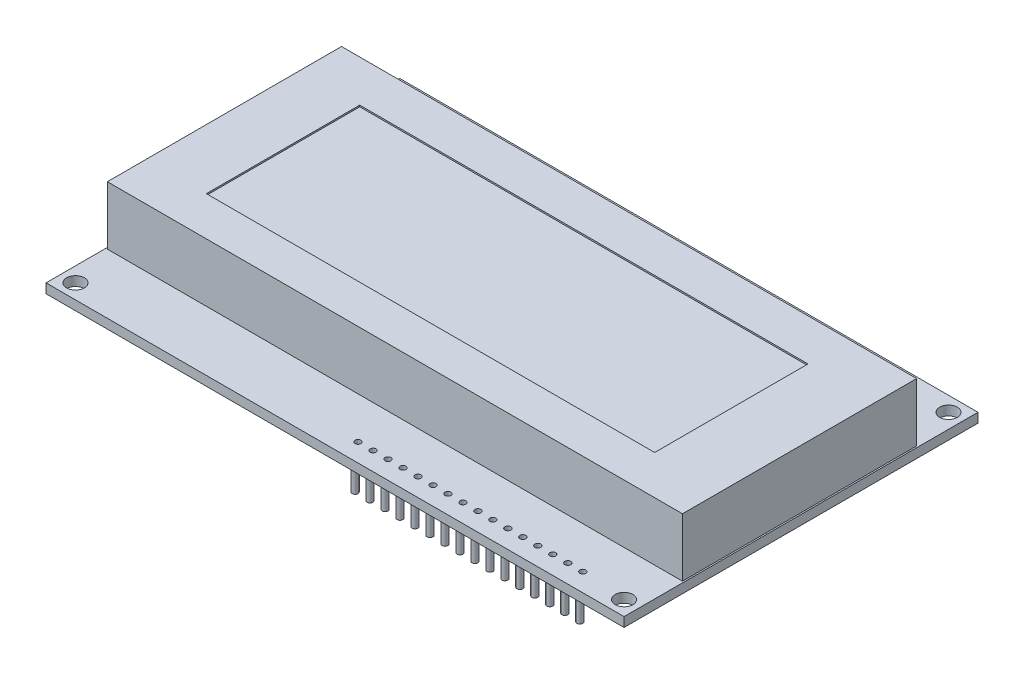
from build123d import *

# Parameters (mm, degrees)
SKETCH1_W                        = 98
SKETCH1_H                        = 60
PCB_BOARD_DEPTH                  = 1.6
SKETCH4_R                        = 1.5
MOUNTING_HOLES_DEPTH             = 1.6
SKETCH5_R                        = 0.5
PCB_HOLES_DEPTH                  = 1.6
SKETCH6_R                        = 0.5
HEADERS_DEPTH                    = 6
SKETCH2_W                        = 97.5
SKETCH2_H                        = 39.7
BLACK_LCD_FRAME_DEPTH            = 9.9
SKETCH7_W                        = 11
SKETCH7_H                        = 3
WHITE_PART_THAT_STICKS_OUT_DEPTH = 2.17
SKETCH3_W                        = 76
SKETCH3_H                        = 26
LCD_SCREEN_DEPTH                 = 0.254
SKETCH8_W                        = 0.692608048
SKETCH8_H                        = 3.684694504
SKETCH8_W_2                      = 0.346304024
SKETCH8_H_2                      = 4.398048289
SKETCH8_W_3                      = 1.171927017
SKETCH8_W_4                      = 1.009844095
SKETCH8_W_5                      = 1.057933222
SKETCH8_W_6                      = 0.585963509
BOSS_EXTRUDE1_DEPTH              = 2.5


with BuildPart() as part:
    # Sketch1 → PCB board (new body)
    with BuildSketch(Plane(origin=(0, 0, 0), x_dir=(1, 0, 0), z_dir=(0, 1, 0))):
        with Locations((-23.16287695, -6.675720991)):
            Rectangle(SKETCH1_W, SKETCH1_H)
    extrude(amount=PCB_BOARD_DEPTH)

    # Sketch4 → Mounting holes (cut)
    with BuildSketch(Plane(origin=(0, 1.6, 0), x_dir=(1, 0, 0), z_dir=(0, 1, 0))):
        with Locations((23.33712305, 20.824279009)):
            Circle(SKETCH4_R)
        with Locations((-69.66287695, -34.175720991)):
            Circle(SKETCH4_R)
        with Locations((-69.66287695, 20.824279009)):
            Circle(SKETCH4_R)
        with Locations((23.33712305, -34.175720991)):
            Circle(SKETCH4_R)
    extrude(amount=-MOUNTING_HOLES_DEPTH, mode=Mode.SUBTRACT)

    # Sketch5 → PCB holes (cut)
    with BuildSketch(Plane(origin=(0, 1.6, 0), x_dir=(1, 0, 0), z_dir=(0, 1, 0))):
        with Locations((15.73712305, -33.575720991)):
            Circle(SKETCH5_R)
        with Locations((13.19712305, -33.575720991)):
            Circle(SKETCH5_R)
        with Locations((10.65712305, -33.575720991)):
            Circle(SKETCH5_R)
        with Locations((8.11712305, -33.575720991)):
            Circle(SKETCH5_R)
        with Locations((5.57712305, -33.575720991)):
            Circle(SKETCH5_R)
        with Locations((3.03712305, -33.575720991)):
            Circle(SKETCH5_R)
        with Locations((0.49712305, -33.575720991)):
            Circle(SKETCH5_R)
        with Locations((-2.04287695, -33.575720991)):
            Circle(SKETCH5_R)
        with Locations((-4.58287695, -33.575720991)):
            Circle(SKETCH5_R)
        with Locations((-7.12287695, -33.575720991)):
            Circle(SKETCH5_R)
        with Locations((-9.66287695, -33.575720991)):
            Circle(SKETCH5_R)
        with Locations((-12.20287695, -33.575720991)):
            Circle(SKETCH5_R)
        with Locations((-14.74287695, -33.575720991)):
            Circle(SKETCH5_R)
        with Locations((-17.28287695, -33.575720991)):
            Circle(SKETCH5_R)
        with Locations((-19.82287695, -33.575720991)):
            Circle(SKETCH5_R)
        with Locations((-22.36287695, -33.575720991)):
            Circle(SKETCH5_R)
    extrude(amount=-PCB_HOLES_DEPTH, mode=Mode.SUBTRACT)

    # Sketch6 → Headers (add)
    with BuildSketch(Plane.XZ):
        with Locations((-22.86287695, 33.575720991)):
            Circle(SKETCH6_R)
        with Locations((-20.32287695, 33.575720991)):
            Circle(SKETCH6_R)
        with Locations((-17.78287695, 33.575720991)):
            Circle(SKETCH6_R)
        with Locations((-15.24287695, 33.575720991)):
            Circle(SKETCH6_R)
        with Locations((-12.70287695, 33.575720991)):
            Circle(SKETCH6_R)
        with Locations((-10.16287695, 33.575720991)):
            Circle(SKETCH6_R)
        with Locations((-7.62287695, 33.575720991)):
            Circle(SKETCH6_R)
        with Locations((-5.08287695, 33.575720991)):
            Circle(SKETCH6_R)
        with Locations((-2.54287695, 33.575720991)):
            Circle(SKETCH6_R)
        with Locations((-0.00287695, 33.575720991)):
            Circle(SKETCH6_R)
        with Locations((2.53712305, 33.575720991)):
            Circle(SKETCH6_R)
        with Locations((5.07712305, 33.575720991)):
            Circle(SKETCH6_R)
        with Locations((7.61712305, 33.575720991)):
            Circle(SKETCH6_R)
        with Locations((10.15712305, 33.575720991)):
            Circle(SKETCH6_R)
        with Locations((12.69712305, 33.575720991)):
            Circle(SKETCH6_R)
        with Locations((15.23712305, 33.575720991)):
            Circle(SKETCH6_R)
    extrude(amount=HEADERS_DEPTH)

    # Sketch2 → Black LCD frame (add)
    with BuildSketch(Plane(origin=(0, 1.6, 0), x_dir=(1, 0, 0), z_dir=(0, 1, 0))):
        with Locations((-23.16287695, -6.675720991)):
            Rectangle(SKETCH2_W, SKETCH2_H)
    extrude(amount=BLACK_LCD_FRAME_DEPTH)

    # Sketch7 → White part that sticks out (add)
    with BuildSketch(Plane.ZY.offset(71.91287695)):
        with Locations((5.5, 3.1)):
            Rectangle(SKETCH7_W, SKETCH7_H)
    extrude(amount=WHITE_PART_THAT_STICKS_OUT_DEPTH)

    # Sketch3 → LCD screen (cut)
    with BuildSketch(Plane(origin=(0, 11.5, 0), x_dir=(1, 0, 0), z_dir=(0, 1, 0))):
        with Locations((-23.766549937, -6.888251248)):
            Rectangle(SKETCH3_W, SKETCH3_H)
    extrude(amount=-LCD_SCREEN_DEPTH, mode=Mode.SUBTRACT)

    # Sketch8 → Boss-Extrude1 (add)
    with BuildSketch(Plane.XZ):
        with Locations((-65.871568973, 28.956578117)):
            Rectangle(SKETCH8_W, SKETCH8_H)
        with Locations((-65.698416961, -15.916426138)):
            Rectangle(SKETCH8_W_2, SKETCH8_H_2)
        with Locations((-26.349706369, -15.916426138)):
            Rectangle(SKETCH8_W_3, SKETCH8_H_2)
        with Locations((17.054029789, -15.916426138)):
            Rectangle(SKETCH8_W_4, SKETCH8_H_2)
        with Locations((18.087918447, 28.956578117)):
            Rectangle(SKETCH8_W_5, SKETCH8_H)
        with Locations((-26.642688123, 28.956578117)):
            Rectangle(SKETCH8_W_6, SKETCH8_H)
    extrude(amount=BOSS_EXTRUDE1_DEPTH)


solid = part.part
